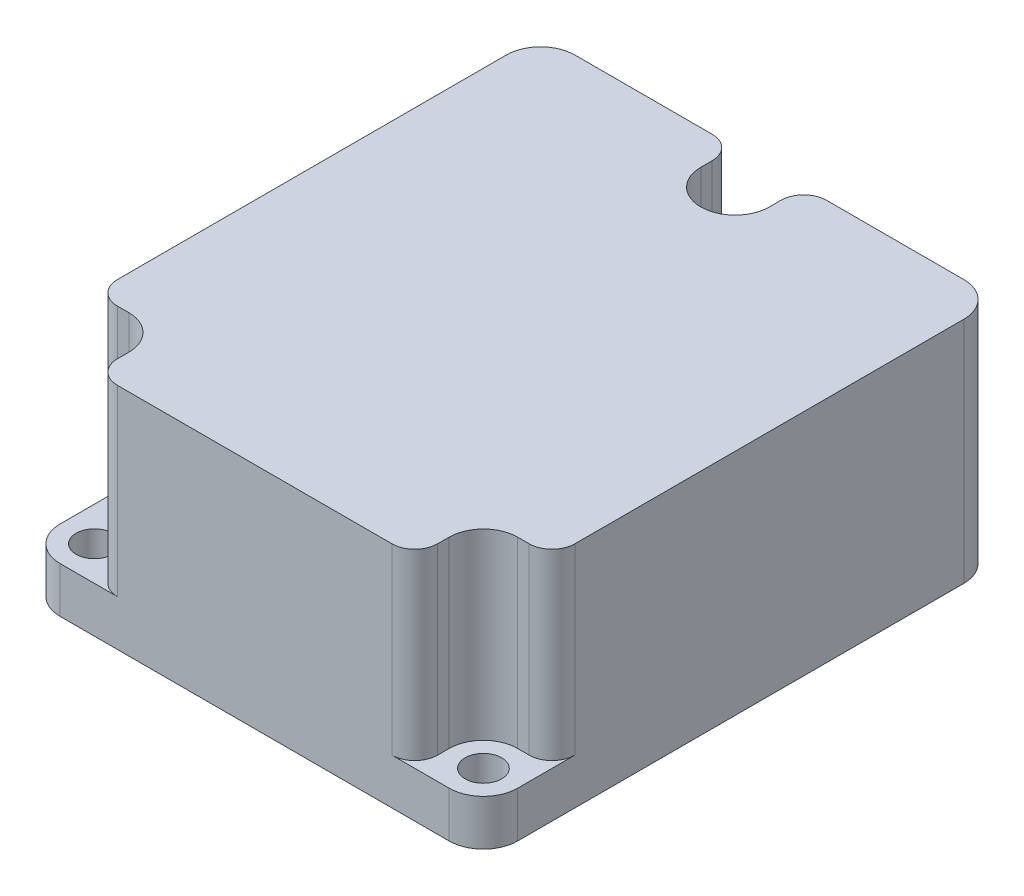
from build123d import *

# Parameters (mm, degrees)
SKETCH_1_R          = 1.6
EXTRUDE_1_DEPTH     = 20
SKETCH_2_R          = 1.6
CUT_EXTRUDE_1_DEPTH = 16
FILLET_1_R          = 2
SKETCH_3_R          = 7
EXTRUDE_2_DEPTH     = 50
SKETCH_4_R          = 7
CUT_EXTRUDE_2_DEPTH = 50


with BuildPart() as part:
    # 草图1 → 凸台-拉伸1 (new body)
    with BuildSketch(Plane(origin=(0, 0, 0), x_dir=(1, 0, 0), z_dir=(0, 1, 0))):
        with BuildLine():
            Line((3, 0), (37, 0))
            ThreePointArc((37, 0), (39.121320344, -0.878679656), (40, -3))
            Line((40, -3), (40, -42))
            ThreePointArc((40, -42), (39.121320344, -44.121320344), (37, -45))
            Line((37, -45), (3, -45))
            ThreePointArc((3, -45), (0.878679656, -44.121320344), (0, -42))
            Line((0, -42), (0, -3))
            ThreePointArc((0, -3), (0.878679656, -0.878679656), (3, 0))
        make_face()
        with Locations((20, -3)):
            Circle(SKETCH_1_R, mode=Mode.SUBTRACT)
        with Locations((3, -42)):
            Circle(SKETCH_1_R, mode=Mode.SUBTRACT)
        with Locations((37, -42)):
            Circle(SKETCH_1_R, mode=Mode.SUBTRACT)
    extrude(amount=EXTRUDE_1_DEPTH)

    # 草图2 → 切除-拉伸1 (cut)
    with BuildSketch(Plane(origin=(0, 20, 0), x_dir=(1, 0, 0), z_dir=(0, 1, 0))):
        with BuildLine():
            Line((40, -42), (40, -39))
            Line((40, -39), (37, -39))
            ThreePointArc((37, -39), (34.878679656, -39.878679656), (34, -42))
            Line((34, -42), (34, -45))
            Line((34, -45), (37, -45))
            ThreePointArc((37, -45), (39.121320344, -44.121320344), (40, -42))
        make_face()
        with Locations((37, -42)):
            Circle(SKETCH_2_R, mode=Mode.SUBTRACT)
        with BuildLine():
            Line((3, -39), (0, -39))
            Line((0, -39), (0, -42))
            ThreePointArc((0, -42), (0.878679656, -44.121320344), (3, -45))
            Line((3, -45), (6, -45))
            Line((6, -45), (6, -42))
            ThreePointArc((6, -42), (5.121320344, -39.878679656), (3, -39))
        make_face()
        with Locations((3, -42)):
            Circle(SKETCH_2_R, mode=Mode.SUBTRACT)
        with BuildLine():
            Line((17, 0), (17, -3))
            ThreePointArc((17, -3), (20, -6), (23, -3))
            Line((23, -3), (23, 0))
            Line((23, 0), (17, 0))
        make_face()
        with Locations((20, -3)):
            Circle(SKETCH_2_R, mode=Mode.SUBTRACT)
    extrude(amount=-CUT_EXTRUDE_1_DEPTH, mode=Mode.SUBTRACT)

    # 圆角1
    fillet_1_edges = [part.edges().sort_by_distance(p)[0] for p in [
        (40, 12, 39),
        (34, 12, 45),
        (6, 12, 45),
        (0, 12, 39),
        (17, 12, 0),
        (23, 12, 0),
    ]]
    fillet(fillet_1_edges, radius=FILLET_1_R)

    # 草图3 → 凸台-拉伸2 (add)
    with BuildSketch(Plane.XY.offset(45)):
        with Locations((20, 10)):
            Circle(SKETCH_3_R)
    extrude(amount=EXTRUDE_2_DEPTH)

    # 草图4 → 切除-拉伸2 (cut)
    with BuildSketch(Plane.XY.offset(95)):
        with Locations((20, 10)):
            Circle(SKETCH_4_R)
    extrude(amount=-CUT_EXTRUDE_2_DEPTH, mode=Mode.SUBTRACT)


solid = part.part
